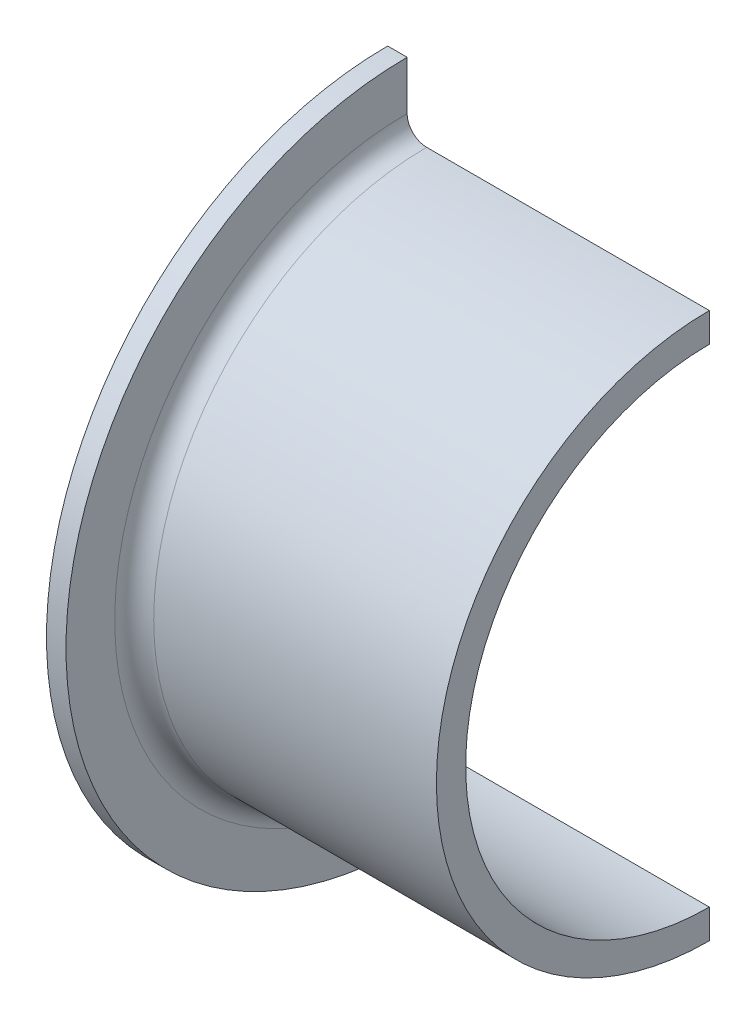
from build123d import *

# Parameters (mm, degrees)
OBR_T1_ANGLE = 180


with BuildPart() as part:
    # Szkic1 → Obrót1 (revolve)
    with BuildSketch(Plane.XY):
        with BuildLine():
            Line((16.5, 12.5), (1, 12.5))
            ThreePointArc((1, 12.5), (0.292893219, 12.792893219), (0, 13.5))
            Line((0, 13.5), (0, 17.5))
            Line((0, 17.5), (1, 17.5))
            Line((1, 17.5), (1, 15))
            ThreePointArc((1, 15), (1.292893219, 14.292893219), (2, 14))
            Line((2, 14), (16.5, 14))
            Line((16.5, 14), (16.5, 12.5))
        make_face()
    revolve(axis=Axis((0, 0, 0), (1, 0, 0)), revolution_arc=OBR_T1_ANGLE)


solid = part.part
